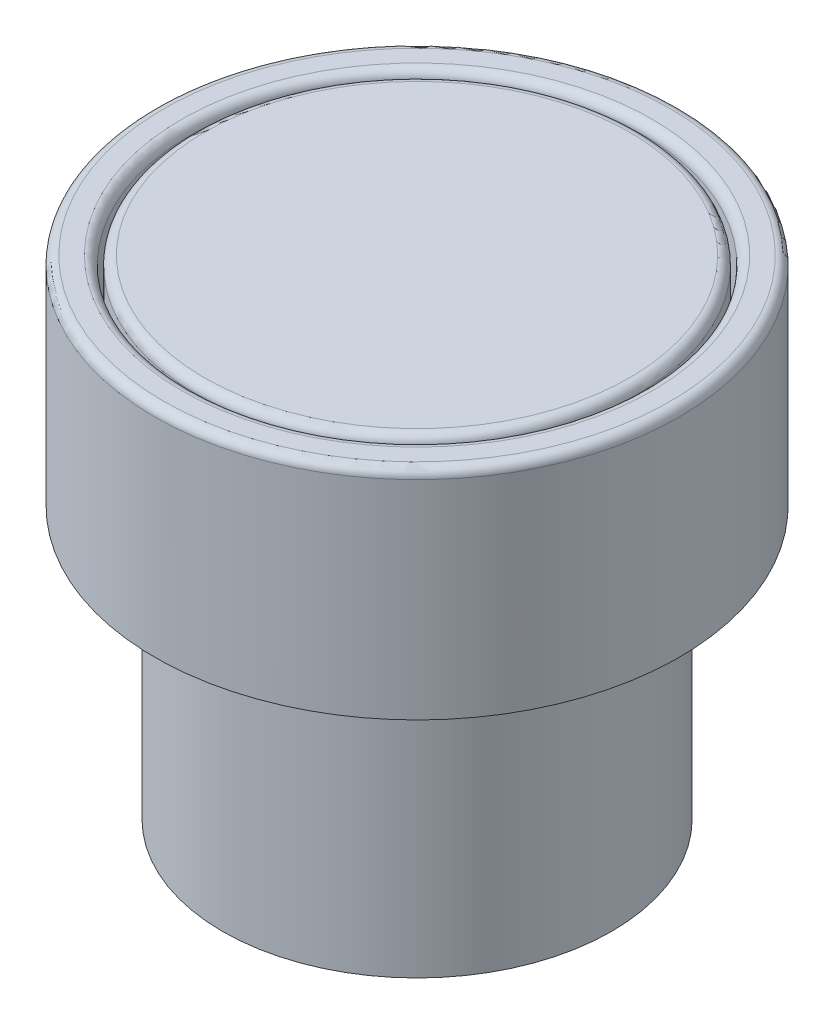
from build123d import *

# Parameters (mm, degrees)
SKETCH1_R           = 14.5
SKETCH1_R_2         = 12.5
BOSS_EXTRUDE1_DEPTH = 11
SKETCH2_R           = 14.5
BOSS_EXTRUDE2_DEPTH = 1
SKETCH3_R           = 10.75
BOSS_EXTRUDE3_DEPTH = 15
SKETCH4_R           = 12.25
BOSS_EXTRUDE4_DEPTH = 11
FILLET1_R           = 0.5


with BuildPart() as part:
    # Sketch1 → Boss-Extrude1 (new body)
    with BuildSketch(Plane(origin=(0, 0, 0), x_dir=(1, 0, 0), z_dir=(0, 1, 0))):
        Circle(SKETCH1_R)
        Circle(SKETCH1_R_2, mode=Mode.SUBTRACT)
    extrude(amount=BOSS_EXTRUDE1_DEPTH)

    # Sketch2 → Boss-Extrude2 (add)
    with BuildSketch(Plane(origin=(0, 0, 0), x_dir=(-1, 0, 0), z_dir=(0, -1, 0))):
        Circle(SKETCH2_R)
    extrude(amount=BOSS_EXTRUDE2_DEPTH)

    # Sketch3 → Boss-Extrude3 (add)
    with BuildSketch(Plane.XZ.offset(1)):
        Circle(SKETCH3_R)
    extrude(amount=BOSS_EXTRUDE3_DEPTH)

    # Sketch4 → Boss-Extrude4 (add)
    with BuildSketch(Plane(origin=(0, 0, 0), x_dir=(1, 0, 0), z_dir=(0, 1, 0))):
        Circle(SKETCH4_R)
    extrude(amount=BOSS_EXTRUDE4_DEPTH)

    # Fillet1
    fillet1_edges = [part.edges().sort_by_distance(p)[0] for p in [
        (-12.25, 11, 0),
        (-14.5, 11, 0),
        (-12.5, 11, 0),
    ]]
    fillet(fillet1_edges, radius=FILLET1_R)


solid = part.part
